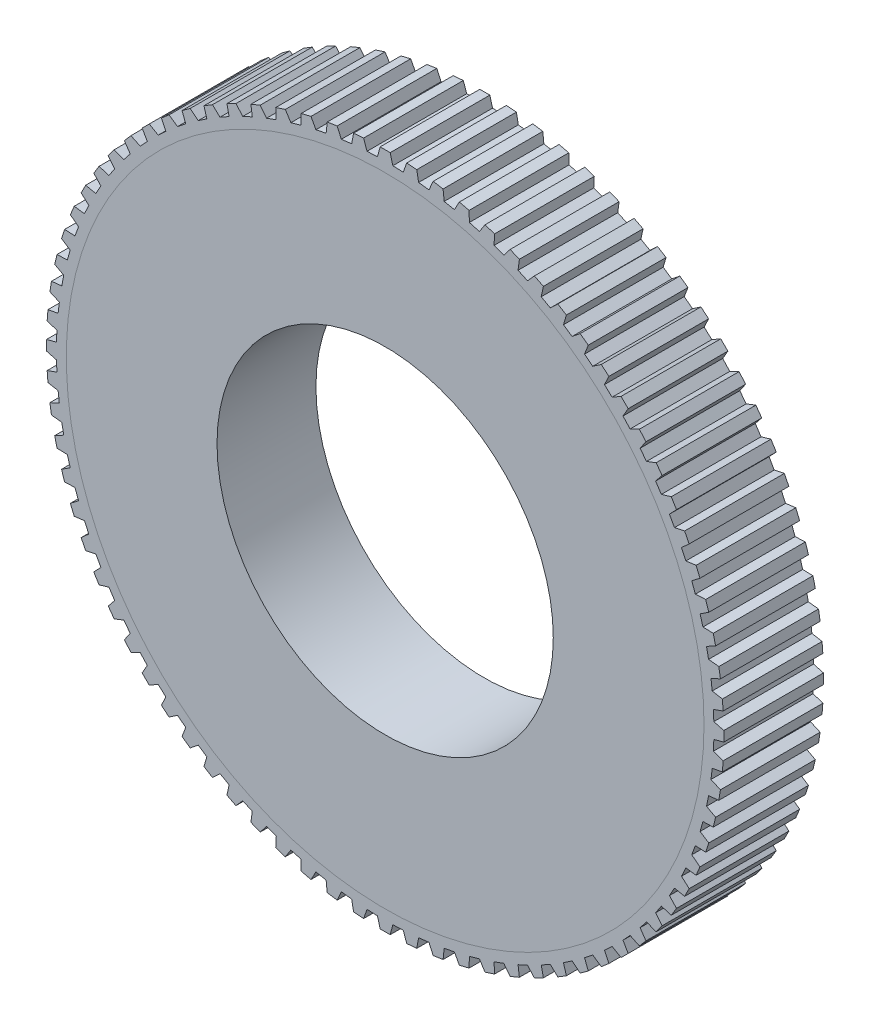
from build123d import *

# Parameters (mm, degrees)
SKETCH1_R                = 16.12
SKETCH1_R_2              = 8.5
BOSS_EXTRUDE1_DEPTH      = 2.5
SKETCH2_R                = 16.12
BOSS_EXTRUDE2_DEPTH      = 2.5
BOSS_EXTRUDE2_DEPTH_BACK = 2.54


with BuildPart() as part:
    # Sketch1 → Boss-Extrude1 (new body, symmetric)
    with BuildSketch(Plane.XY):
        Circle(SKETCH1_R)
        Circle(SKETCH1_R_2, mode=Mode.SUBTRACT)
    extrude(amount=BOSS_EXTRUDE1_DEPTH, both=True)


with BuildPart() as body_2:
    # Sketch2 → Boss-Extrude2 (new body, two sides)
    with BuildSketch(Plane.XY) as boss_extrude2_sk:
        Polygon((-0.254, 17.12), (0.254, 17.12), (0.389195798, 16.615442415), (0.91563655, 16.594758501), (1.090002716, 17.087153364), (1.596436722, 17.047296143), (1.691628624, 16.5336866), (2.214823694, 16.471762383), (2.427285203, 16.948958745), (2.92903088, 16.869490037), (2.983631997, 16.34999511), (3.500355713, 16.247212373), (3.749602669, 16.70626816), (4.243566589, 16.587677915), (4.257240287, 16.065500463), (4.764306876, 15.922492895), (5.048802589, 16.360577876), (5.531939299, 16.203597242), (5.504601275, 15.681956664), (5.998884502, 15.499605954), (6.316874961, 15.914019188), (6.786205763, 15.719616005), (6.718024565, 15.201728387), (7.19647701, 14.981158788), (7.546001698, 15.369345281), (7.998633013, 15.138718107), (7.890029, 14.627776399), (8.349700845, 14.370347797), (8.728604826, 14.729914249), (9.16174603, 14.464484978), (9.013388783, 13.963639306), (9.451445997, 13.670938832), (9.857393203, 13.999668398), (10.268373836, 13.70107349), (10.081178026, 13.213411732), (10.494919842, 12.887243984), (10.925407472, 13.183109935), (11.311693703, 12.853190327), (11.086813455, 12.381719082), (11.473689016, 12.024094991), (11.926062971, 12.285273216), (12.285273216, 11.926062971), (12.024094991, 11.473689016), (12.381719082, 11.086813455), (12.853190327, 11.311693703), (13.183109935, 10.925407472), (12.887243984, 10.494919842), (13.213411732, 10.081178026), (13.70107349, 10.268373836), (13.999668398, 9.857393203), (13.670938832, 9.451445997), (13.963639306, 9.013388783), (14.464484978, 9.16174603), (14.729914249, 8.728604826), (14.370347797, 8.349700845), (14.627776399, 7.890029), (15.138718107, 7.998633013), (15.369345281, 7.546001698), (14.981158788, 7.19647701), (15.201728387, 6.718024565), (15.719616005, 6.786205763), (15.914019188, 6.316874961), (15.499605954, 5.998884502), (15.681956664, 5.504601275), (16.203597242, 5.531939299), (16.360577876, 5.048802589), (15.922492895, 4.764306876), (16.065500463, 4.257240287), (16.587677915, 4.243566589), (16.70626816, 3.749602669), (16.247212373, 3.500355713), (16.34999511, 2.983631997), (16.869490037, 2.92903088), (16.948958745, 2.427285203), (16.471762383, 2.214823694), (16.5336866, 1.691628624), (17.047296143, 1.596436722), (17.087153364, 1.090002716), (16.594758501, 0.91563655), (16.615442415, 0.389195798), (17.12, 0.254), (17.12, -0.254), (16.615442415, -0.389195798), (16.594758501, -0.91563655), (17.087153364, -1.090002716), (17.047296143, -1.596436722), (16.5336866, -1.691628624), (16.471762383, -2.214823694), (16.948958745, -2.427285203), (16.869490037, -2.92903088), (16.34999511, -2.983631997), (16.247212373, -3.500355713), (16.70626816, -3.749602669), (16.587677915, -4.243566589), (16.065500463, -4.257240287), (15.922492895, -4.764306876), (16.360577876, -5.048802589), (16.203597242, -5.531939299), (15.681956664, -5.504601275), (15.499605954, -5.998884502), (15.914019188, -6.316874961), (15.719616005, -6.786205763), (15.201728387, -6.718024565), (14.981158788, -7.19647701), (15.369345281, -7.546001698), (15.138718107, -7.998633013), (14.627776399, -7.890029), (14.370347797, -8.349700845), (14.729914249, -8.728604826), (14.464484978, -9.16174603), (13.963639306, -9.013388783), (13.670938832, -9.451445997), (13.999668398, -9.857393203), (13.70107349, -10.268373836), (13.213411732, -10.081178026), (12.887243984, -10.494919842), (13.183109935, -10.925407472), (12.853190327, -11.311693703), (12.381719082, -11.086813455), (12.024094991, -11.473689016), (12.285273216, -11.926062971), (11.926062971, -12.285273216), (11.473689016, -12.024094991), (11.086813455, -12.381719082), (11.311693703, -12.853190327), (10.925407472, -13.183109935), (10.494919842, -12.887243984), (10.081178026, -13.213411732), (10.268373836, -13.70107349), (9.857393203, -13.999668398), (9.451445997, -13.670938832), (9.013388783, -13.963639306), (9.16174603, -14.464484978), (8.728604826, -14.729914249), (8.349700845, -14.370347797), (7.890029, -14.627776399), (7.998633013, -15.138718107), (7.546001698, -15.369345281), (7.19647701, -14.981158788), (6.718024565, -15.201728387), (6.786205763, -15.719616005), (6.316874961, -15.914019188), (5.998884502, -15.499605954), (5.504601275, -15.681956664), (5.531939299, -16.203597242), (5.048802589, -16.360577876), (4.764306876, -15.922492895), (4.257240287, -16.065500463), (4.243566589, -16.587677915), (3.749602669, -16.70626816), (3.500355713, -16.247212373), (2.983631997, -16.34999511), (2.92903088, -16.869490037), (2.427285203, -16.948958745), (2.214823694, -16.471762383), (1.691628624, -16.5336866), (1.596436722, -17.047296143), (1.090002716, -17.087153364), (0.91563655, -16.594758501), (0.389195798, -16.615442415), (0.254, -17.12), (-0.254, -17.12), (-0.389195798, -16.615442415), (-0.91563655, -16.594758501), (-1.090002716, -17.087153364), (-1.596436722, -17.047296143), (-1.691628624, -16.5336866), (-2.214823694, -16.471762383), (-2.427285203, -16.948958745), (-2.92903088, -16.869490037), (-2.983631997, -16.34999511), (-3.500355713, -16.247212373), (-3.749602669, -16.70626816), (-4.243566589, -16.587677915), (-4.257240287, -16.065500463), (-4.764306876, -15.922492895), (-5.048802589, -16.360577876), (-5.531939299, -16.203597242), (-5.504601275, -15.681956664), (-5.998884502, -15.499605954), (-6.316874961, -15.914019188), (-6.786205763, -15.719616005), (-6.718024565, -15.201728387), (-7.19647701, -14.981158788), (-7.546001698, -15.369345281), (-7.998633013, -15.138718107), (-7.890029, -14.627776399), (-8.349700845, -14.370347797), (-8.728604826, -14.729914249), (-9.16174603, -14.464484978), (-9.013388783, -13.963639306), (-9.451445997, -13.670938832), (-9.857393203, -13.999668398), (-10.268373836, -13.70107349), (-10.081178026, -13.213411732), (-10.494919842, -12.887243984), (-10.925407472, -13.183109935), (-11.311693703, -12.853190327), (-11.086813455, -12.381719082), (-11.473689016, -12.024094991), (-11.926062971, -12.285273216), (-12.285273216, -11.926062971), (-12.024094991, -11.473689016), (-12.381719082, -11.086813455), (-12.853190327, -11.311693703), (-13.183109935, -10.925407472), (-12.887243984, -10.494919842), (-13.213411732, -10.081178026), (-13.70107349, -10.268373836), (-13.999668398, -9.857393203), (-13.670938832, -9.451445997), (-13.963639306, -9.013388783), (-14.464484978, -9.16174603), (-14.729914249, -8.728604826), (-14.370347797, -8.349700845), (-14.627776399, -7.890029), (-15.138718107, -7.998633013), (-15.369345281, -7.546001698), (-14.981158788, -7.19647701), (-15.201728387, -6.718024565), (-15.719616005, -6.786205763), (-15.914019188, -6.316874961), (-15.499605954, -5.998884502), (-15.681956664, -5.504601275), (-16.203597242, -5.531939299), (-16.360577876, -5.048802589), (-15.922492895, -4.764306876), (-16.065500463, -4.257240287), (-16.587677915, -4.243566589), (-16.70626816, -3.749602669), (-16.247212373, -3.500355713), (-16.34999511, -2.983631997), (-16.869490037, -2.92903088), (-16.948958745, -2.427285203), (-16.471762383, -2.214823694), (-16.5336866, -1.691628624), (-17.047296143, -1.596436722), (-17.087153364, -1.090002716), (-16.594758501, -0.91563655), (-16.615442415, -0.389195798), (-17.12, -0.254), (-17.12, 0.254), (-16.615442415, 0.389195798), (-16.594758501, 0.91563655), (-17.087153364, 1.090002716), (-17.047296143, 1.596436722), (-16.5336866, 1.691628624), (-16.471762383, 2.214823694), (-16.948958745, 2.427285203), (-16.869490037, 2.92903088), (-16.34999511, 2.983631997), (-16.247212373, 3.500355713), (-16.70626816, 3.749602669), (-16.587677915, 4.243566589), (-16.065500463, 4.257240287), (-15.922492895, 4.764306876), (-16.360577876, 5.048802589), (-16.203597242, 5.531939299), (-15.681956664, 5.504601275), (-15.499605954, 5.998884502), (-15.914019188, 6.316874961), (-15.719616005, 6.786205763), (-15.201728387, 6.718024565), (-14.981158788, 7.19647701), (-15.369345281, 7.546001698), (-15.138718107, 7.998633013), (-14.627776399, 7.890029), (-14.370347797, 8.349700845), (-14.729914249, 8.728604826), (-14.464484978, 9.16174603), (-13.963639306, 9.013388783), (-13.670938832, 9.451445997), (-13.999668398, 9.857393203), (-13.70107349, 10.268373836), (-13.213411732, 10.081178026), (-12.887243984, 10.494919842), (-13.183109935, 10.925407472), (-12.853190327, 11.311693703), (-12.381719082, 11.086813455), (-12.024094991, 11.473689016), (-12.285273216, 11.926062971), (-11.926062971, 12.285273216), (-11.473689016, 12.024094991), (-11.086813455, 12.381719082), (-11.311693703, 12.853190327), (-10.925407472, 13.183109935), (-10.494919842, 12.887243984), (-10.081178026, 13.213411732), (-10.268373836, 13.70107349), (-9.857393203, 13.999668398), (-9.451445997, 13.670938832), (-9.013388783, 13.963639306), (-9.16174603, 14.464484978), (-8.728604826, 14.729914249), (-8.349700845, 14.370347797), (-7.890029, 14.627776399), (-7.998633013, 15.138718107), (-7.546001698, 15.369345281), (-7.19647701, 14.981158788), (-6.718024565, 15.201728387), (-6.786205763, 15.719616005), (-6.316874961, 15.914019188), (-5.998884502, 15.499605954), (-5.504601275, 15.681956664), (-5.531939299, 16.203597242), (-5.048802589, 16.360577876), (-4.764306876, 15.922492895), (-4.257240287, 16.065500463), (-4.243566589, 16.587677915), (-3.749602669, 16.70626816), (-3.500355713, 16.247212373), (-2.983631997, 16.34999511), (-2.92903088, 16.869490037), (-2.427285203, 16.948958745), (-2.214823694, 16.471762383), (-1.691628624, 16.5336866), (-1.596436722, 17.047296143), (-1.090002716, 17.087153364), (-0.91563655, 16.594758501), (-0.389195798, 16.615442415), align=None)
        Circle(SKETCH2_R, mode=Mode.SUBTRACT)
    extrude(amount=BOSS_EXTRUDE2_DEPTH)
    extrude(boss_extrude2_sk.sketch, amount=-BOSS_EXTRUDE2_DEPTH_BACK)


solid = Compound([part.part, body_2.part])
